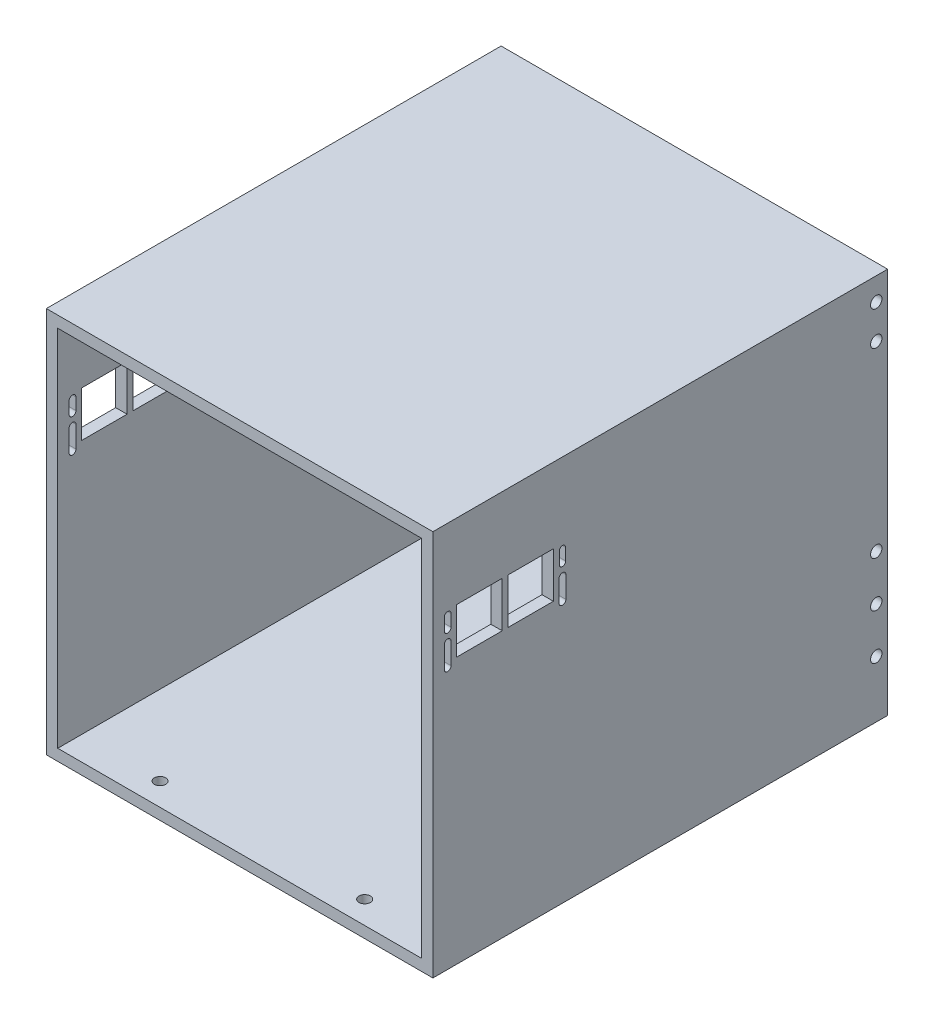
from build123d import *

# Parameters (mm, degrees)
SKETCH1_W           = 215.9
SKETCH1_H           = 215.9
SKETCH1_W_2         = 203.2
SKETCH1_H_2         = 203.2
BOSS_EXTRUDE1_DEPTH = 254
SKETCH2_W           = 25.4
SKETCH2_H           = 25.4
CUT_EXTRUDE1_DEPTH  = 216.9
SKETCH5_R           = 3.175
CUT_EXTRUDE4_DEPTH  = 6.35
SKETCH6_R           = 3.180077948
CUT_EXTRUDE5_DEPTH  = 216.9
SKETCH7_R           = 3.175
CUT_EXTRUDE6_DEPTH  = 12.7


with BuildPart() as part:
    # Sketch1 → Boss-Extrude1 (new body)
    with BuildSketch(Plane.XY):
        Rectangle(SKETCH1_W, SKETCH1_H)
        Rectangle(SKETCH1_W_2, SKETCH1_H_2, mode=Mode.SUBTRACT)
    extrude(amount=BOSS_EXTRUDE1_DEPTH)

    # Sketch2 → Cut-Extrude1 (cut, through all)
    with BuildSketch(Plane(origin=(107.95, 0, 0), x_dir=(0, 0, -1), z_dir=(1, 0, 0))):
        with Locations((-227.976799094, 53.34)):
            Rectangle(SKETCH2_W, SKETCH2_H)
        with Locations((-199.401799094, 53.34)):
            Rectangle(SKETCH2_W, SKETCH2_H)
        with BuildLine():
            Line((-243.851799094, 50.053361626), (-243.851799094, 38.064561626))
            ThreePointArc((-243.851799094, 38.064561626), (-245.750899547, 36.165461173), (-247.65, 38.064561626))
            Line((-247.65, 38.064561626), (-247.65, 50.053361626))
            ThreePointArc((-247.65, 50.053361626), (-245.750899547, 51.952462079), (-243.851799094, 50.053361626))
        make_face()
        with BuildLine():
            Line((-247.65, 56.682761626), (-247.65, 63.287106941))
            ThreePointArc((-247.65, 63.287106941), (-245.750899547, 65.186207394), (-243.851799094, 63.287106941))
            Line((-243.851799094, 63.287106941), (-243.851799094, 56.682761626))
            ThreePointArc((-243.851799094, 56.682761626), (-245.750899547, 54.783661173), (-247.65, 56.682761626))
        make_face()
        with BuildLine():
            Line((-179.728598189, 50.053361626), (-179.728598189, 38.064561626))
            ThreePointArc((-179.728598189, 38.064561626), (-181.627698642, 36.165461173), (-183.526799094, 38.064561626))
            Line((-183.526799094, 38.064561626), (-183.526799094, 50.053361626))
            ThreePointArc((-183.526799094, 50.053361626), (-181.627698642, 51.952462079), (-179.728598189, 50.053361626))
        make_face()
        with BuildLine():
            Line((-183.405698642, 56.682761626), (-183.405698642, 63.287106941))
            ThreePointArc((-183.405698642, 63.287106941), (-181.627698642, 65.065106941), (-179.849698642, 63.287106941))
            Line((-179.849698642, 63.287106941), (-179.849698642, 56.682761626))
            ThreePointArc((-179.849698642, 56.682761626), (-181.627698642, 54.904761626), (-183.405698642, 56.682761626))
        make_face()
    extrude(amount=-CUT_EXTRUDE1_DEPTH, mode=Mode.SUBTRACT)

    # Sketch5 → Cut-Extrude4 (cut)
    with BuildSketch(Plane.XZ.offset(107.95)):
        with Locations((-76.2, 6.35)):
            Circle(SKETCH5_R)
        with Locations((-50.8, 6.35)):
            Circle(SKETCH5_R)
        with Locations((0, 6.35)):
            Circle(SKETCH5_R)
        with Locations((25.4, 6.35)):
            Circle(SKETCH5_R)
    extrude(amount=-CUT_EXTRUDE4_DEPTH, mode=Mode.SUBTRACT)

    # Sketch6 → Cut-Extrude5 (cut, through all)
    with BuildSketch(Plane(origin=(107.95, 0, 0), x_dir=(0, 0, -1), z_dir=(1, 0, 0))):
        with Locations((-6.35, 95.25)):
            Circle(SKETCH6_R)
        with Locations((-6.35, 76.2)):
            Circle(SKETCH6_R)
        with Locations((-6.35, -25.4)):
            Circle(SKETCH6_R)
        with Locations((-6.35, -50.8)):
            Circle(SKETCH6_R)
        with Locations((-6.35, -76.2)):
            Circle(SKETCH6_R)
    extrude(amount=-CUT_EXTRUDE5_DEPTH, mode=Mode.SUBTRACT)

    # Sketch7 → Cut-Extrude6 (cut)
    with BuildSketch(Plane(origin=(0, -101.6, 0), x_dir=(1, 0, 0), z_dir=(0, 1, 0))):
        with Locations((-57.15, -241.3)):
            Circle(SKETCH7_R)
        with Locations((57.15, -241.3)):
            Circle(SKETCH7_R)
    extrude(amount=-CUT_EXTRUDE6_DEPTH, mode=Mode.SUBTRACT)


solid = part.part
